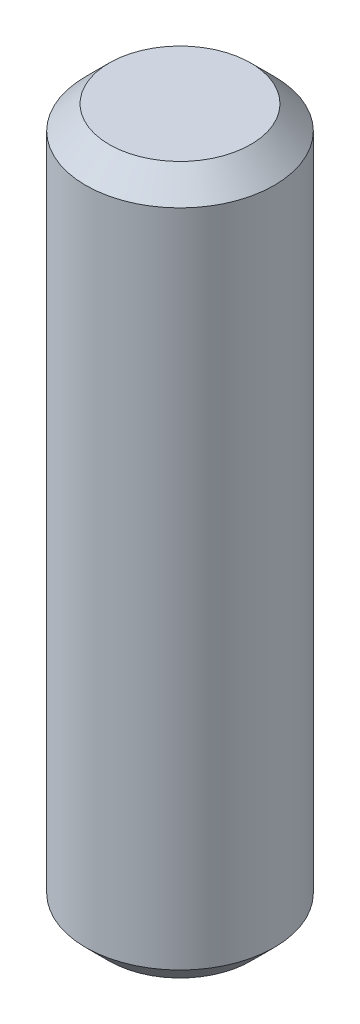
from build123d import *

# Parameters (mm, degrees)
SKETCH_1_R      = 2
EXTRUDE_1_DEPTH = 15
CHAMFER_1_SIZE  = 0.5
CHAMFER_2_SIZE  = 0.5


with BuildPart() as part:
    # 草圖1 → 填料-伸長1 (new body)
    with BuildSketch(Plane(origin=(0, 0, 0), x_dir=(1, 0, 0), z_dir=(0, 1, 0))):
        Circle(SKETCH_1_R)
    extrude(amount=EXTRUDE_1_DEPTH)

    # 導角1
    chamfer_1_edges = [part.edges().sort_by_distance(p)[0] for p in [
        (-2, 15, 0),
    ]]
    chamfer(chamfer_1_edges, length=CHAMFER_1_SIZE)

    # 導角2
    chamfer_2_edges = [part.edges().sort_by_distance(p)[0] for p in [
        (-2, 0, 0),
    ]]
    chamfer(chamfer_2_edges, length=CHAMFER_2_SIZE)


solid = part.part
